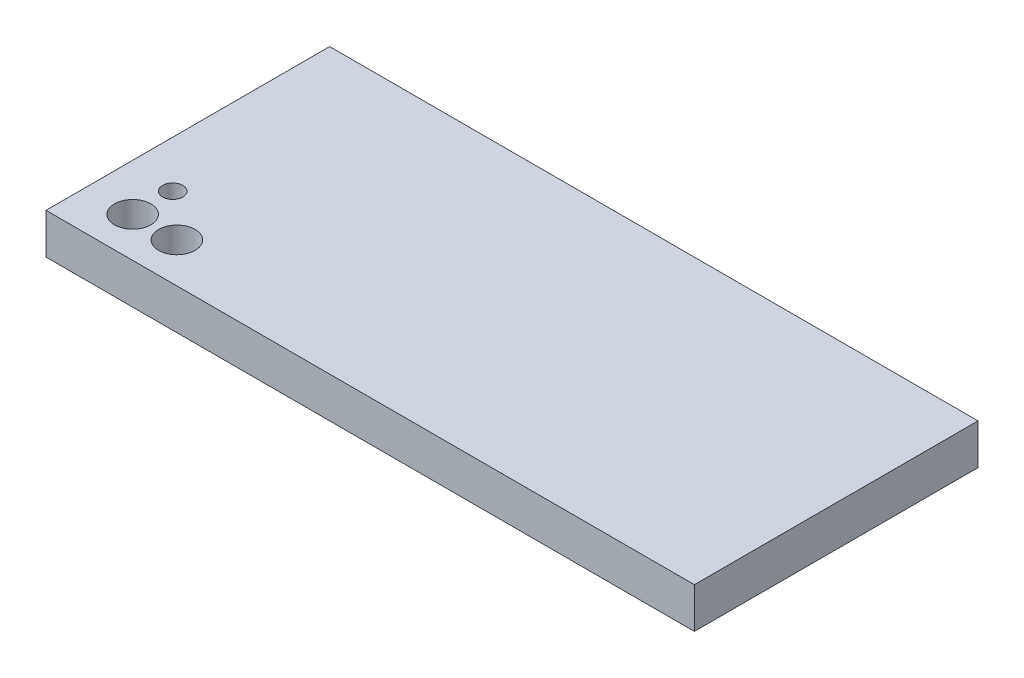
from build123d import *

# Parameters (mm, degrees)
SKETCH1_W           = 160
SKETCH1_H           = 70
SKETCH1_R           = 4.5
SKETCH1_R_2         = 2.5
BOSS_EXTRUDE1_DEPTH = 10


with BuildPart() as part:
    # Sketch1 → Boss-Extrude1 (new body)
    with BuildSketch(Plane(origin=(0, 0, 0), x_dir=(1, 0, 0), z_dir=(0, 1, 0))):
        Rectangle(SKETCH1_W, SKETCH1_H)
        with Locations((-68.446114543, -25.169889981)):
            Circle(SKETCH1_R, mode=Mode.SUBTRACT)
        with Locations((-68.446114543, -15.283664996)):
            Circle(SKETCH1_R_2, mode=Mode.SUBTRACT)
        with Locations((-57.5311771, -25.169889981)):
            Circle(SKETCH1_R, mode=Mode.SUBTRACT)
    extrude(amount=-BOSS_EXTRUDE1_DEPTH)


solid = part.part
